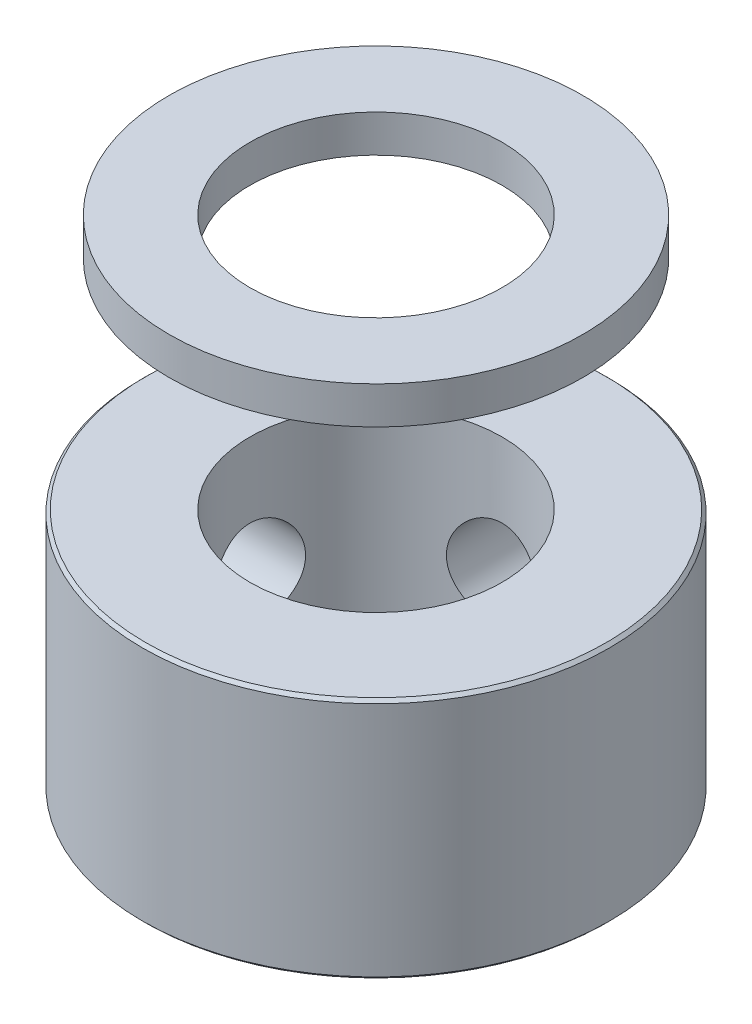
from build123d import *

# Parameters (mm, degrees)
P_IDAT_START            = 7.8
SKICA1_R                = 2.5
P_IDAT_VYSUNUT_M1_DEPTH = 7
SKICA2_R                = 3.5
SKICA2_R_2              = 2.5
P_IDAT_VYSUNUT_M2_DEPTH = 7.8
SKICA3_R                = 3.5
SKICA3_R_2              = 2.5
P_IDAT_VYSUNUT_M3_DEPTH = 1.2
SKICA5_R                = 7.5
SKICA5_R_2              = 3.5
P_IDAT_VYSUNUT_M4_DEPTH = 1.2
SKICA6_R                = 7.5
SKICA6_R_2              = 3.5
P_IDAT_VYSUNUT_M5_DEPTH = 7.8
ZKOSEN_1_SIZE           = 0.1
ZKOSEN_2_SIZE           = 0.1
ZKOSEN_3_SIZE           = 0.1
SKETCH8_OUTSIDE_W       = 22.314
SKETCH8_OUTSIDE_H       = 22.314
SKETCH8_OUTSIDE_R       = 6.65
CUT_EXTRUDE2_DEPTH      = 5
SKETCH19_R              = 1.5
CUT_EXTRUDE6_DEPTH      = 5
SKETCH20_R              = 1.5
CUT_EXTRUDE7_DEPTH      = 5
SKETCH7_R               = 4.05
CUT_EXTRUDE9_DEPTH      = 20
SKETCH27_R              = 7.4
CUT_EXTRUDE12_DEPTH     = 7


with BuildPart() as part:
    # Skica1 → Přidat vysunutím1 (new body)
    with BuildSketch(Plane(origin=(0, 0, 0), x_dir=(1, 0, 0), z_dir=(0, 1, 0)).offset(P_IDAT_START)):
        with BuildLine():
            ThreePointArc((-5.730143195, 1.098270155), (-5.09645097, 1.530497044), (-5.387174672, 2.240331989))
            ThreePointArc((-5.387174672, 2.240331989), (-5.468060657, 2.292707421), (-5.540463547, 2.356296335))
            ThreePointArc((-5.540463547, 2.356296335), (-5.573874331, 2.399596558), (-5.596043873, 2.44959357))
            ThreePointArc((-5.596043873, 2.44959357), (-5.50369925, 2.650567912), (-5.404139771, 2.848067596))
            ThreePointArc((-5.404139771, 2.848067596), (-5.351227535, 2.86190541), (-5.296542742, 2.862779021))
            ThreePointArc((-5.296542742, 2.862779021), (-5.201685094, 2.845815675), (-5.110305882, 2.815228615))
            ThreePointArc((-5.110305882, 2.815228615), (-4.374063308, 3.030479148), (-4.431206919, 3.795410862))
            ThreePointArc((-4.431206919, 3.795410862), (-4.491949163, 3.870218002), (-4.541158349, 3.953068377))
            ThreePointArc((-4.541158349, 3.953068377), (-4.559553388, 4.004573836), (-4.565187949, 4.058974585))
            ThreePointArc((-4.565187949, 4.058974585), (-4.415258506, 4.221576484), (-4.259541056, 4.378644275))
            ThreePointArc((-4.259541056, 4.378644275), (-4.204942409, 4.375454038), (-4.15266412, 4.359386362))
            ThreePointArc((-4.15266412, 4.359386362), (-4.067691098, 4.313940635), (-3.990236225, 4.256612884))
            ThreePointArc((-3.990236225, 4.256612884), (-3.223511854, 4.233816838), (-3.041481758, 4.978968476))
            ThreePointArc((-3.041481758, 4.978968476), (-3.076134388, 5.06888468), (-3.097332931, 5.162886543))
            ThreePointArc((-3.097332931, 5.162886543), (-3.09891159, 5.217555525), (-3.08745962, 5.271034888))
            ThreePointArc((-3.08745962, 5.271034888), (-2.894621497, 5.379347737), (-2.697988784, 5.480608745))
            ThreePointArc((-2.697988784, 5.480608745), (-2.647048223, 5.460702739), (-2.6022938, 5.429266591))
            ThreePointArc((-2.6022938, 5.429266591), (-2.535523156, 5.359787029), (-2.479574443, 5.281330225))
            ThreePointArc((-2.479574443, 5.281330225), (-1.7574206, 5.022719037), (-1.354035171, 5.675149965))
            ThreePointArc((-1.354035171, 5.675149965), (-1.359206146, 5.771373608), (-1.350318985, 5.867325402))
            ThreePointArc((-1.350318985, 5.867325402), (-1.334926735, 5.919806527), (-1.307509232, 5.967129569))
            ThreePointArc((-1.307509232, 5.967129569), (-1.090638767, 6.010550954), (-0.872338572, 6.046093045))
            ThreePointArc((-0.872338572, 6.046093045), (-0.830042514, 6.01141981), (-0.797192832, 5.967692379))
            ThreePointArc((-0.797192832, 5.967692379), (-0.755160541, 5.880980125), (-0.726194639, 5.789074167))
            ThreePointArc((-0.726194639, 5.789074167), (-0.119300773, 5.319962501), (0.465953812, 5.815808234))
            ThreePointArc((0.465953812, 5.815808234), (0.490770664, 5.908920276), (0.528873591, 5.997429571))
            ThreePointArc((0.528873591, 5.997429571), (0.55973005, 6.04258562), (0.600429269, 6.079120034))
            ThreePointArc((0.600429269, 6.079120034), (0.820103284, 6.053399565), (1.038702217, 6.019743632))
            ThreePointArc((1.038702217, 6.019743632), (1.06821354, 5.973697225), (1.085942924, 5.921958857))
            ThreePointArc((1.085942924, 5.921958857), (1.099122448, 5.826501911), (1.098270155, 5.730143195))
            ThreePointArc((1.098270155, 5.730143195), (1.530497044, 5.09645097), (2.240331989, 5.387174672))
            ThreePointArc((2.240331989, 5.387174672), (2.292707421, 5.468060657), (2.356296335, 5.540463547))
            ThreePointArc((2.356296335, 5.540463547), (2.399596558, 5.573874331), (2.44959357, 5.596043873))
            ThreePointArc((2.44959357, 5.596043873), (2.650567912, 5.50369925), (2.848067596, 5.404139771))
            ThreePointArc((2.848067596, 5.404139771), (2.86190541, 5.351227535), (2.862779021, 5.296542742))
            ThreePointArc((2.862779021, 5.296542742), (2.845815675, 5.201685094), (2.815228615, 5.110305882))
            ThreePointArc((2.815228615, 5.110305882), (3.030479148, 4.374063308), (3.795410862, 4.431206919))
            ThreePointArc((3.795410862, 4.431206919), (3.870218002, 4.491949163), (3.953068377, 4.541158349))
            ThreePointArc((3.953068377, 4.541158349), (4.004573836, 4.559553388), (4.058974585, 4.565187949))
            ThreePointArc((4.058974585, 4.565187949), (4.221576484, 4.415258506), (4.378644275, 4.259541056))
            ThreePointArc((4.378644275, 4.259541056), (4.375454038, 4.204942409), (4.359386362, 4.15266412))
            ThreePointArc((4.359386362, 4.15266412), (4.313940635, 4.067691098), (4.256612884, 3.990236225))
            ThreePointArc((4.256612884, 3.990236225), (4.233816838, 3.223511854), (4.978968476, 3.041481758))
            ThreePointArc((4.978968476, 3.041481758), (5.06888468, 3.076134388), (5.162886543, 3.097332931))
            ThreePointArc((5.162886543, 3.097332931), (5.217555525, 3.09891159), (5.271034888, 3.08745962))
            ThreePointArc((5.271034888, 3.08745962), (5.379347737, 2.894621497), (5.480608745, 2.697988784))
            ThreePointArc((5.480608745, 2.697988784), (5.460702739, 2.647048223), (5.429266591, 2.6022938))
            ThreePointArc((5.429266591, 2.6022938), (5.359787029, 2.535523156), (5.281330225, 2.479574443))
            ThreePointArc((5.281330225, 2.479574443), (5.022719037, 1.7574206), (5.675149965, 1.354035171))
            ThreePointArc((5.675149965, 1.354035171), (5.771373608, 1.359206146), (5.867325402, 1.350318985))
            ThreePointArc((5.867325402, 1.350318985), (5.919806527, 1.334926735), (5.967129569, 1.307509232))
            ThreePointArc((5.967129569, 1.307509232), (6.010550954, 1.090638767), (6.046093045, 0.872338572))
            ThreePointArc((6.046093045, 0.872338572), (6.01141981, 0.830042514), (5.967692379, 0.797192832))
            ThreePointArc((5.967692379, 0.797192832), (5.880980125, 0.755160541), (5.789074167, 0.726194639))
            ThreePointArc((5.789074167, 0.726194639), (5.319962501, 0.119300773), (5.815808234, -0.465953812))
            ThreePointArc((5.815808234, -0.465953812), (5.908920276, -0.490770664), (5.997429571, -0.528873591))
            ThreePointArc((5.997429571, -0.528873591), (6.04258562, -0.55973005), (6.079120034, -0.600429269))
            ThreePointArc((6.079120034, -0.600429269), (6.053399565, -0.820103284), (6.019743632, -1.038702217))
            ThreePointArc((6.019743632, -1.038702217), (5.973697225, -1.06821354), (5.921958857, -1.085942924))
            ThreePointArc((5.921958857, -1.085942924), (5.826501911, -1.099122448), (5.730143195, -1.098270155))
            ThreePointArc((5.730143195, -1.098270155), (5.09645097, -1.530497044), (5.387174672, -2.240331989))
            ThreePointArc((5.387174672, -2.240331989), (5.468060657, -2.292707421), (5.540463547, -2.356296335))
            ThreePointArc((5.540463547, -2.356296335), (5.573874331, -2.399596558), (5.596043873, -2.44959357))
            ThreePointArc((5.596043873, -2.44959357), (5.50369925, -2.650567911), (5.404139771, -2.848067596))
            ThreePointArc((5.404139771, -2.848067596), (5.351227535, -2.86190541), (5.296542742, -2.862779021))
            ThreePointArc((5.296542742, -2.862779021), (5.201685094, -2.845815675), (5.110305882, -2.815228615))
            ThreePointArc((5.110305882, -2.815228615), (4.374063308, -3.030479148), (4.431206919, -3.795410862))
            ThreePointArc((4.431206919, -3.795410862), (4.491949163, -3.870218002), (4.541158349, -3.953068377))
            ThreePointArc((4.541158349, -3.953068377), (4.559553388, -4.004573836), (4.565187949, -4.058974585))
            ThreePointArc((4.565187949, -4.058974585), (4.415258506, -4.221576484), (4.259541056, -4.378644275))
            ThreePointArc((4.259541056, -4.378644275), (4.204942409, -4.375454038), (4.15266412, -4.359386362))
            ThreePointArc((4.15266412, -4.359386362), (4.067691098, -4.313940635), (3.990236225, -4.256612884))
            ThreePointArc((3.990236225, -4.256612884), (3.223511854, -4.233816838), (3.041481758, -4.978968476))
            ThreePointArc((3.041481758, -4.978968476), (3.076134388, -5.06888468), (3.097332931, -5.162886543))
            ThreePointArc((3.097332931, -5.162886543), (3.09891159, -5.217555525), (3.08745962, -5.271034888))
            ThreePointArc((3.08745962, -5.271034888), (2.894621497, -5.379347737), (2.697988784, -5.480608745))
            ThreePointArc((2.697988784, -5.480608745), (2.647048223, -5.460702739), (2.6022938, -5.429266591))
            ThreePointArc((2.6022938, -5.429266591), (2.535523156, -5.359787029), (2.479574443, -5.281330225))
            ThreePointArc((2.479574443, -5.281330225), (1.7574206, -5.022719037), (1.354035171, -5.675149965))
            ThreePointArc((1.354035171, -5.675149965), (1.359206146, -5.771373608), (1.350318985, -5.867325402))
            ThreePointArc((1.350318985, -5.867325402), (1.334926735, -5.919806527), (1.307509232, -5.967129569))
            ThreePointArc((1.307509232, -5.967129569), (1.090638767, -6.010550954), (0.872338572, -6.046093045))
            ThreePointArc((0.872338572, -6.046093045), (0.830042514, -6.01141981), (0.797192832, -5.967692379))
            ThreePointArc((0.797192832, -5.967692379), (0.755160541, -5.880980125), (0.726194639, -5.789074167))
            ThreePointArc((0.726194639, -5.789074167), (0.119300773, -5.319962501), (-0.465953812, -5.815808234))
            ThreePointArc((-0.465953812, -5.815808234), (-0.490770664, -5.908920276), (-0.528873591, -5.997429571))
            ThreePointArc((-0.528873591, -5.997429571), (-0.55973005, -6.04258562), (-0.600429269, -6.079120034))
            ThreePointArc((-0.600429269, -6.079120034), (-0.820103284, -6.053399565), (-1.038702217, -6.019743632))
            ThreePointArc((-1.038702217, -6.019743632), (-1.06821354, -5.973697225), (-1.085942924, -5.921958857))
            ThreePointArc((-1.085942924, -5.921958857), (-1.099122448, -5.826501911), (-1.098270155, -5.730143195))
            ThreePointArc((-1.098270155, -5.730143195), (-1.530497044, -5.09645097), (-2.240331989, -5.387174672))
            ThreePointArc((-2.240331989, -5.387174672), (-2.292707421, -5.468060657), (-2.356296335, -5.540463547))
            ThreePointArc((-2.356296335, -5.540463547), (-2.399596558, -5.573874331), (-2.44959357, -5.596043873))
            ThreePointArc((-2.44959357, -5.596043873), (-2.650567912, -5.50369925), (-2.848067596, -5.404139771))
            ThreePointArc((-2.848067596, -5.404139771), (-2.86190541, -5.351227535), (-2.862779021, -5.296542742))
            ThreePointArc((-2.862779021, -5.296542742), (-2.845815675, -5.201685094), (-2.815228615, -5.110305882))
            ThreePointArc((-2.815228615, -5.110305882), (-3.030479148, -4.374063308), (-3.795410862, -4.431206919))
            ThreePointArc((-3.795410862, -4.431206919), (-3.870218002, -4.491949163), (-3.953068377, -4.541158349))
            ThreePointArc((-3.953068377, -4.541158349), (-4.004573836, -4.559553388), (-4.058974585, -4.565187949))
            ThreePointArc((-4.058974585, -4.565187949), (-4.221576484, -4.415258506), (-4.378644275, -4.259541056))
            ThreePointArc((-4.378644275, -4.259541056), (-4.375454038, -4.204942409), (-4.359386362, -4.15266412))
            ThreePointArc((-4.359386362, -4.15266412), (-4.313940635, -4.067691098), (-4.256612884, -3.990236225))
            ThreePointArc((-4.256612884, -3.990236225), (-4.233816838, -3.223511854), (-4.978968476, -3.041481758))
            ThreePointArc((-4.978968476, -3.041481758), (-5.06888468, -3.076134388), (-5.162886543, -3.097332931))
            ThreePointArc((-5.162886543, -3.097332931), (-5.217555525, -3.09891159), (-5.271034888, -3.08745962))
            ThreePointArc((-5.271034888, -3.08745962), (-5.379347737, -2.894621497), (-5.480608745, -2.697988784))
            ThreePointArc((-5.480608745, -2.697988784), (-5.460702739, -2.647048223), (-5.429266591, -2.6022938))
            ThreePointArc((-5.429266591, -2.6022938), (-5.359787029, -2.535523156), (-5.281330225, -2.479574443))
            ThreePointArc((-5.281330225, -2.479574443), (-5.022719037, -1.7574206), (-5.675149965, -1.354035171))
            ThreePointArc((-5.675149965, -1.354035171), (-5.771373608, -1.359206146), (-5.867325402, -1.350318985))
            ThreePointArc((-5.867325402, -1.350318985), (-5.919806527, -1.334926735), (-5.967129569, -1.307509232))
            ThreePointArc((-5.967129569, -1.307509232), (-6.010550954, -1.090638767), (-6.046093045, -0.872338572))
            ThreePointArc((-6.046093045, -0.872338572), (-6.01141981, -0.830042514), (-5.967692379, -0.797192832))
            ThreePointArc((-5.967692379, -0.797192832), (-5.880980125, -0.755160541), (-5.789074167, -0.726194639))
            ThreePointArc((-5.789074167, -0.726194639), (-5.319962501, -0.119300773), (-5.815808234, 0.465953812))
            ThreePointArc((-5.815808234, 0.465953812), (-5.908920276, 0.490770664), (-5.997429571, 0.528873591))
            ThreePointArc((-5.997429571, 0.528873591), (-6.04258562, 0.55973005), (-6.079120034, 0.600429269))
            ThreePointArc((-6.079120034, 0.600429269), (-6.053399565, 0.820103284), (-6.019743632, 1.038702217))
            ThreePointArc((-6.019743632, 1.038702217), (-5.973697225, 1.06821354), (-5.921958857, 1.085942924))
            ThreePointArc((-5.921958857, 1.085942924), (-5.826501911, 1.099122448), (-5.730143195, 1.098270155))
        make_face()
        Circle(SKICA1_R, mode=Mode.SUBTRACT)
    extrude(amount=P_IDAT_VYSUNUT_M1_DEPTH)

    # Skica2 → Přidat vysunutím2 (add)
    with BuildSketch(Plane.XZ.offset(-7.8)):
        Circle(SKICA2_R)
        Circle(SKICA2_R_2, mode=Mode.SUBTRACT)
    extrude(amount=P_IDAT_VYSUNUT_M2_DEPTH)

    # Skica3 → Přidat vysunutím3 (add)
    with BuildSketch(Plane(origin=(0, 14.8, 0), x_dir=(1, 0, 0), z_dir=(0, 1, 0))):
        Circle(SKICA3_R)
        Circle(SKICA3_R_2, mode=Mode.SUBTRACT)
    extrude(amount=P_IDAT_VYSUNUT_M3_DEPTH)

    # Zkosení2
    zkosen_2_edges = [part.edges().sort_by_distance(p)[0] for p in [
        (-2.5, 0, 0),
        (-2.5, 16, 0),
    ]]
    chamfer(zkosen_2_edges, length=ZKOSEN_2_SIZE)


with BuildPart() as body_2:
    # Skica5 → Přidat vysunutím4 (new body)
    with BuildSketch(Plane(origin=(0, 16, 0), x_dir=(1, 0, 0), z_dir=(0, 1, 0))):
        Circle(SKICA5_R)
        Circle(SKICA5_R_2, mode=Mode.SUBTRACT)
    extrude(amount=-P_IDAT_VYSUNUT_M4_DEPTH)

    # Zkosení1
    zkosen_1_edges = [body_2.edges().sort_by_distance(p)[0] for p in [
        (-7.5, 16, 0),
        (-7.5, 14.8, 0),
    ]]
    chamfer(zkosen_1_edges, length=ZKOSEN_1_SIZE)

    # Sketch8 outside → Cut-Extrude2 (cut)
    with BuildSketch(Plane(origin=(0, 16, 0), x_dir=(1, 0, 0), z_dir=(0, 1, 0))):
        Rectangle(SKETCH8_OUTSIDE_W, SKETCH8_OUTSIDE_H)
        Circle(SKETCH8_OUTSIDE_R, mode=Mode.SUBTRACT)
    extrude(amount=-CUT_EXTRUDE2_DEPTH, mode=Mode.SUBTRACT)


with BuildPart() as body_3:
    # Skica6 → Přidat vysunutím5 (new body)
    with BuildSketch(Plane.XZ):
        Circle(SKICA6_R)
        Circle(SKICA6_R_2, mode=Mode.SUBTRACT)
    extrude(amount=-P_IDAT_VYSUNUT_M5_DEPTH)

    # Zkosení3
    zkosen_3_edges = [body_3.edges().sort_by_distance(p)[0] for p in [
        (-7.5, 0, 0),
        (-7.5, 7.8, 0),
    ]]
    chamfer(zkosen_3_edges, length=ZKOSEN_3_SIZE)

    # Sketch19 → Cut-Extrude6 (cut)
    with BuildSketch(Plane(origin=(0, 0, -7.5), x_dir=(-1, 0, 0), z_dir=(0, 0, -1))):
        with Locations((0, 3.9)):
            Circle(SKETCH19_R)
    extrude(amount=-CUT_EXTRUDE6_DEPTH, mode=Mode.SUBTRACT)

    # Sketch20 → Cut-Extrude7 (cut)
    with BuildSketch(Plane.ZY.offset(7.5)):
        with Locations((0, 3.9)):
            Circle(SKETCH20_R)
    extrude(amount=-CUT_EXTRUDE7_DEPTH, mode=Mode.SUBTRACT)


with BuildPart() as cut_extrude9_tool:
    # Sketch7 → Cut-Extrude9 (new body)
    with BuildSketch(Plane.XZ):
        Circle(SKETCH7_R)
    extrude(amount=-CUT_EXTRUDE9_DEPTH)


with BuildPart() as part_1:
    add(part.part)

    # Cut-Extrude9: cut by cut_extrude9_tool
    add(cut_extrude9_tool.part, mode=Mode.SUBTRACT)

    # Sketch27 → Cut-Extrude12 (cut)
    with BuildSketch(Plane(origin=(0, 7.8, 0), x_dir=(1, 0, 0), z_dir=(0, 1, 0))):
        Circle(SKETCH27_R)
    extrude(amount=CUT_EXTRUDE12_DEPTH, mode=Mode.SUBTRACT)


with BuildPart() as body_2_1:
    add(body_2.part)

    # Cut-Extrude9: cut by cut_extrude9_tool
    add(cut_extrude9_tool.part, mode=Mode.SUBTRACT)


with BuildPart() as body_3_1:
    add(body_3.part)

    # Cut-Extrude9: cut by cut_extrude9_tool
    add(cut_extrude9_tool.part, mode=Mode.SUBTRACT)


solid = Compound([body_2_1.part, body_3_1.part])
